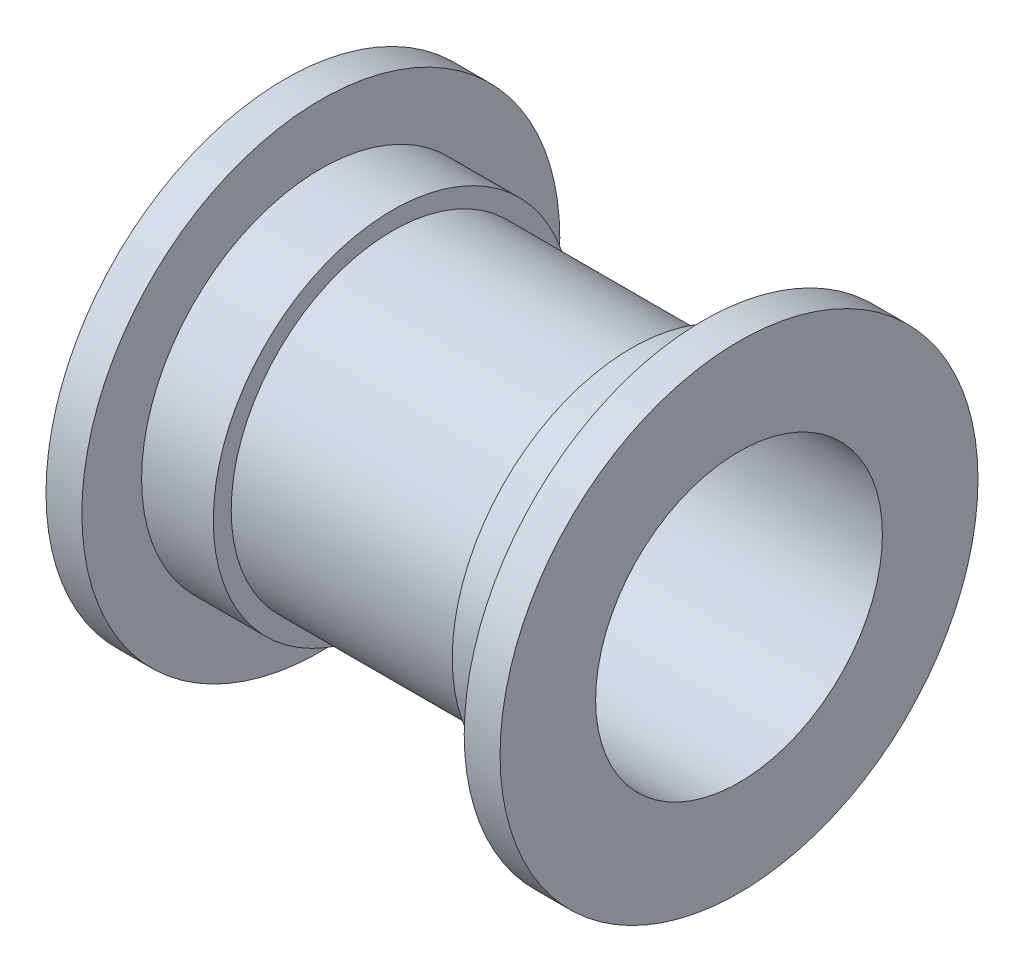
from build123d import *


with BuildPart() as part:
    # Sketch3 → Revolve1 (revolve)
    with BuildSketch(Plane.XY):
        Polygon((30.1625, 31.75), (30.1625, 19.05), (-30.1625, 19.05), (-30.1625, 31.75), (-25.4, 31.75), (-25.4, 23.8125), (-15.875, 23.8125), (-15.875, 21.43125), (15.875, 21.43125), (15.875, 23.8125), (25.4, 23.8125), (25.4, 31.75), align=None)
    revolve(axis=Axis((-30.1625, 0, 0), (1, 0, 0)))


solid = part.part
